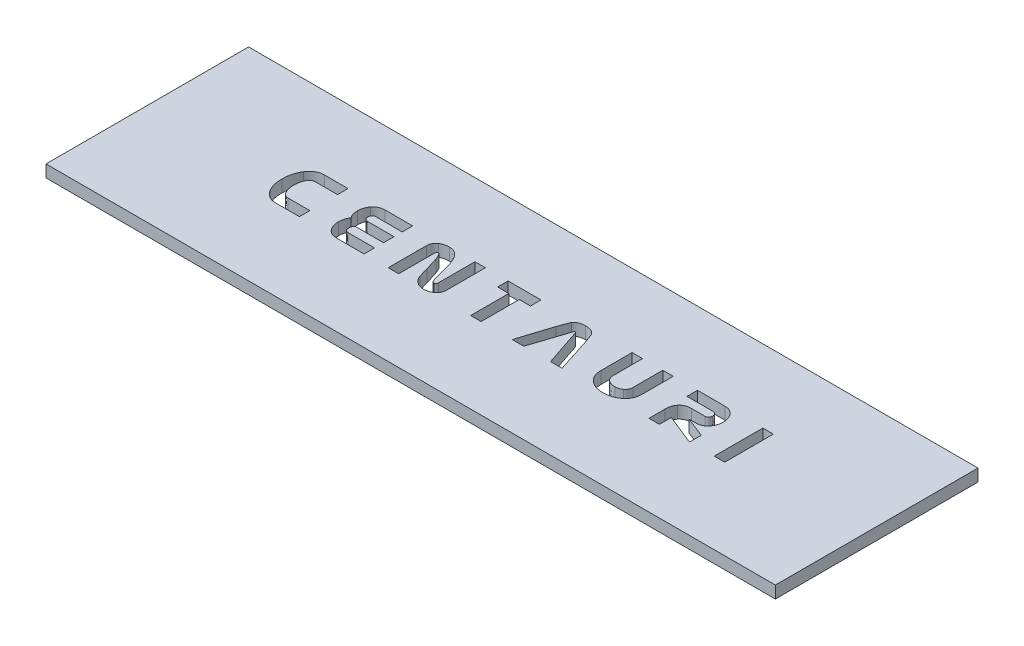
from build123d import *

# Parameters (mm, degrees)
SKETCH1_W           = 180
SKETCH1_H           = 50
BOSS_EXTRUDE1_DEPTH = 3
SKETCH3_W           = 2.584615384
SKETCH3_H           = 12
CUT_EXTRUDE2_DEPTH  = 4


with BuildPart() as part:
    # Sketch1 → Boss-Extrude1 (new body)
    with BuildSketch(Plane(origin=(0, 0, 0), x_dir=(1, 0, 0), z_dir=(0, 1, 0))):
        with Locations((55.306122449, 6.37755102)):
            Rectangle(SKETCH1_W, SKETCH1_H)
    extrude(amount=BOSS_EXTRUDE1_DEPTH)

    # Sketch3 → Cut-Extrude2 (cut, through all)
    with BuildSketch(Plane(origin=(0, 3, 0), x_dir=(1, 0, 0), z_dir=(0, 1, 0))):
        with Locations((111.503045526, 7.37755102)):
            Rectangle(SKETCH3_W, SKETCH3_H)
        with BuildLine():
            Line((104.151314757, 1.331397174), (96.659968603, 4.331397174))
            Line((96.659968603, 4.331397174), (96.659968603, 1.417935636))
            Line((96.659968603, 1.417935636), (94.075353218, 1.417935636))
            Line((94.075353218, 1.417935636), (94.075353218, 5.404474097))
            add(Edge.make_bspline(
                [(94.075353218, 5.404474097), (94.077783488, 5.521837057), (94.082513805, 5.750274291), (94.113135102, 6.085283936), (94.171906372, 6.40214741), (94.249023069, 6.702240314), (94.346736519, 6.986260441), (94.472234096, 7.250443105), (94.614933359, 7.501708858), (94.730342412, 7.653722459), (94.787853218, 7.729474097)],
                knots=[0, 0, 0, 0, 0.000352112, 0.000685357, 0.001007867, 0.001317812, 0.001614311, 0.001907252, 0.002194209, 0.002479247, 0.002479247, 0.002479247, 0.002479247], degree=3))
            add(Edge.make_bspline(
                [(94.787853218, 7.729474097), (94.858869169, 7.81223259), (95.000127593, 7.976848201), (95.247649926, 8.187452071), (95.519848388, 8.364884657), (95.814318465, 8.513126474), (96.135551196, 8.625227764), (96.479630594, 8.70614626), (96.849155289, 8.751411211), (97.103118036, 8.758508537), (97.234007064, 8.762166405)],
                knots=[0, 0, 0, 0, 0.000326765, 0.00064997, 0.000970799, 0.001299759, 0.001636419, 0.001989063, 0.002358305, 0.002750994, 0.002750994, 0.002750994, 0.002750994], degree=3))
            Line((97.234007064, 8.762166405), (100.510930141, 8.762166405))
            add(Edge.make_bspline(
                [(100.510930141, 8.762166405), (100.582506607, 8.764842157), (100.719370969, 8.769958574), (100.912485676, 8.826987129), (101.080457951, 8.919399509), (101.21680336, 9.050471952), (101.325976171, 9.202402027), (101.40501475, 9.372650343), (101.452672185, 9.556691576), (101.457509793, 9.683998568), (101.459968603, 9.748704867)],
                knots=[0, 0, 0, 0, 0.000214162, 0.000409508, 0.00059807, 0.000783787, 0.000971907, 0.001156455, 0.001343955, 0.001537761, 0.001537761, 0.001537761, 0.001537761], degree=3))
            add(Edge.make_bspline(
                [(101.459968603, 9.748704867), (101.457278055, 9.817200113), (101.452028991, 9.950829395), (101.408943785, 10.142726249), (101.333467911, 10.317405253), (101.260032365, 10.417222523), (101.223430141, 10.466974097)],
                knots=[0, 0, 0, 0, 0.000205315, 0.000400555, 0.00058654, 0.000771358, 0.000771358, 0.000771358, 0.000771358], degree=3))
            add(Edge.make_bspline(
                [(101.223430141, 10.466974097), (101.1773741, 10.516398285), (101.086408664, 10.61401616), (100.91438126, 10.719976414), (100.718964682, 10.782200501), (100.581583484, 10.789289736), (100.510930141, 10.792935636)],
                knots=[0, 0, 0, 0, 0.000201944, 0.00039886, 0.000598649, 0.000810192, 0.000810192, 0.000810192, 0.000810192], degree=3))
            Line((100.510930141, 10.792935636), (94.075353218, 10.792935636))
            Line((94.075353218, 10.792935636), (94.075353218, 13.37755102))
            Line((94.075353218, 13.37755102), (100.842660911, 13.37755102))
            add(Edge.make_bspline(
                [(100.842660911, 13.37755102), (100.965911388, 13.374331483), (101.206824993, 13.36803836), (101.559363075, 13.315630576), (101.8906306, 13.225692139), (102.204525917, 13.104512245), (102.495635968, 12.944070138), (102.770199204, 12.752779251), (103.02296361, 12.52360253), (103.170599149, 12.347644425), (103.245545526, 12.258320251)],
                knots=[0, 0, 0, 0, 0.000369636, 0.000722516, 0.001066088, 0.001397668, 0.001729411, 0.002060728, 0.002399716, 0.002749231, 0.002749231, 0.002749231, 0.002749231], degree=3))
            add(Edge.make_bspline(
                [(103.245545526, 12.258320251), (103.309833471, 12.172992361), (103.437980211, 12.00290618), (103.598364999, 11.725901775), (103.738203601, 11.437316772), (103.850902807, 11.1329641), (103.936700108, 10.814032071), (104.000599355, 10.481570877), (104.038831679, 10.134221551), (104.042643998, 9.897839637), (104.044583987, 9.77755102)],
                knots=[0, 0, 0, 0, 0.000320244, 0.000638351, 0.000958322, 0.001281425, 0.001610322, 0.001948068, 0.002296247, 0.002657009, 0.002657009, 0.002657009, 0.002657009], degree=3))
            add(Edge.make_bspline(
                [(104.044583987, 9.77755102), (104.042666603, 9.658218674), (104.038899162, 9.423744332), (104.000252719, 9.078392089), (103.937197062, 8.747666674), (103.850335233, 8.429986266), (103.738268273, 8.12642179), (103.598347939, 7.837858682), (103.437984499, 7.560848558), (103.309834903, 7.390763142), (103.245545526, 7.305435636)],
                knots=[0, 0, 0, 0, 0.000357878, 0.00070319, 0.001040936, 0.001367051, 0.001690154, 0.002010125, 0.002328231, 0.002648476, 0.002648476, 0.002648476, 0.002648476], degree=3))
            add(Edge.make_bspline(
                [(103.245545526, 7.305435636), (103.17079576, 7.214948537), (103.023995192, 7.037241524), (102.769150269, 6.808596118), (102.496729912, 6.613234038), (102.203712279, 6.454410956), (101.891382536, 6.328517828), (101.559249404, 6.239745411), (101.206855323, 6.186990588), (100.965921652, 6.18074582), (100.842660911, 6.17755102)],
                knots=[0, 0, 0, 0, 0.000351687, 0.000690675, 0.001023657, 0.001355401, 0.001688046, 0.002031618, 0.002384497, 0.002754134, 0.002754134, 0.002754134, 0.002754134], degree=3))
            Line((100.842660911, 6.17755102), (99.207083987, 6.17755102))
            Line((99.207083987, 6.17755102), (104.151314757, 4.22755102))
            Line((104.151314757, 4.22755102), (104.151314757, 1.331397174))
        make_face()
        with BuildLine():
            add(Edge.make_bspline(
                [(88.093814757, 5.649666405), (88.088908157, 5.479175628), (88.079322441, 5.146098519), (88.002005461, 4.660533714), (87.879096718, 4.200989134), (87.701799908, 3.767678029), (87.471777305, 3.361572423), (87.193160226, 2.982032936), (86.86494128, 2.628148362), (86.6128026, 2.422716216), (86.484199372, 2.317935636)],
                knots=[0, 0, 0, 0, 0.000511237, 0.000998771, 0.001471117, 0.001935549, 0.002399255, 0.002867745, 0.003345321, 0.003842489, 0.003842489, 0.003842489, 0.003842489], degree=3))
            add(Edge.make_bspline(
                [(86.484199372, 2.317935636), (86.361674204, 2.228175768), (86.116018196, 2.048212327), (85.720443172, 1.819309926), (85.305950446, 1.623832211), (84.869444573, 1.468785737), (84.414394739, 1.344798387), (83.938123961, 1.254604623), (83.44209488, 1.202790729), (83.10451149, 1.196252712), (82.933237834, 1.192935636)],
                knots=[0, 0, 0, 0, 0.000455386, 0.000913022, 0.001368554, 0.001828431, 0.002300777, 0.002782232, 0.003281095, 0.003794848, 0.003794848, 0.003794848, 0.003794848], degree=3))
            add(Edge.make_bspline(
                [(82.933237834, 1.192935636), (82.766748331, 1.196112671), (82.439666017, 1.202354218), (81.958470147, 1.255965147), (81.497135861, 1.341114963), (81.056000515, 1.462633657), (80.636685166, 1.619305377), (80.235329921, 1.807523208), (79.853371451, 2.030872861), (79.618127464, 2.208806704), (79.500545526, 2.297743328)],
                knots=[0, 0, 0, 0, 0.000499339, 0.000980992, 0.001450573, 0.001905465, 0.002351798, 0.002791822, 0.003234101, 0.003676078, 0.003676078, 0.003676078, 0.003676078], degree=3))
            add(Edge.make_bspline(
                [(79.500545526, 2.297743328), (79.375870089, 2.402690242), (79.130792805, 2.608986731), (78.811428291, 2.962038529), (78.541471121, 3.341707351), (78.319991898, 3.749186129), (78.148669968, 4.185260839), (78.029751535, 4.64947359), (77.950671097, 5.140237987), (77.9435913, 5.47722953), (77.939968603, 5.649666405)],
                knots=[0, 0, 0, 0, 0.000488455, 0.000960167, 0.001423594, 0.001883109, 0.002348069, 0.002825244, 0.00331848, 0.003835342, 0.003835342, 0.003835342, 0.003835342], degree=3))
            Line((77.939968603, 5.649666405), (77.939968603, 13.37755102))
            Line((77.939968603, 13.37755102), (80.524583987, 13.37755102))
            Line((80.524583987, 13.37755102), (80.524583987, 6.018897174))
            add(Edge.make_bspline(
                [(80.524583987, 6.018897174), (80.526575463, 5.941831532), (80.530508435, 5.789634341), (80.568342336, 5.56746499), (80.632877855, 5.35775274), (80.720167918, 5.15879812), (80.832590856, 4.971712835), (80.970296286, 4.796572317), (81.132719016, 4.633423035), (81.257033091, 4.538628484), (81.320737834, 4.49005102)],
                knots=[0, 0, 0, 0, 0.000231058, 0.000456316, 0.000673488, 0.000887883, 0.001106543, 0.0013264, 0.00155485, 0.001794967, 0.001794967, 0.001794967, 0.001794967], degree=3))
            add(Edge.make_bspline(
                [(81.320737834, 4.49005102), (81.446072659, 4.40826064), (81.697974565, 4.243875742), (82.128374669, 4.08346305), (82.591452385, 3.977039084), (82.914321348, 3.967217202), (83.080353218, 3.962166405)],
                knots=[0, 0, 0, 0, 0.000447711, 0.000899823, 0.001369457, 0.001866625, 0.001866625, 0.001866625, 0.001866625], degree=3))
            add(Edge.make_bspline(
                [(83.080353218, 3.962166405), (83.239583082, 3.967688164), (83.547641306, 3.97837098), (83.989271864, 4.077136065), (84.396038764, 4.232999572), (84.632842561, 4.391216988), (84.750545526, 4.469858713)],
                knots=[0, 0, 0, 0, 0.000477018, 0.000922875, 0.001351404, 0.001774902, 0.001774902, 0.001774902, 0.001774902], degree=3))
            add(Edge.make_bspline(
                [(84.750545526, 4.469858713), (84.81157644, 4.51731231), (84.931223106, 4.610341634), (85.083787839, 4.774684242), (85.215956847, 4.94873293), (85.323361318, 5.13796288), (85.406690015, 5.340718152), (85.468126465, 5.555291736), (85.502863346, 5.783142798), (85.507051358, 5.938972666), (85.509199372, 6.018897174)],
                knots=[0, 0, 0, 0, 0.000231579, 0.000453994, 0.00067034, 0.000886089, 0.001104655, 0.001326545, 0.001554193, 0.001793893, 0.001793893, 0.001793893, 0.001793893], degree=3))
            Line((85.509199372, 6.018897174), (85.509199372, 13.37755102))
            Line((85.509199372, 13.37755102), (88.093814757, 13.37755102))
            Line((88.093814757, 13.37755102), (88.093814757, 5.649666405))
        make_face()
        with BuildLine():
            Line((72.633430141, 1.37755102), (69.820930141, 1.37755102))
            Line((69.820930141, 1.37755102), (66.714199372, 10.645820251))
            add(Edge.make_bspline(
                [(66.714199372, 10.645820251), (66.708311345, 10.667915948), (66.696906966, 10.710712579), (66.648929228, 10.759425628), (66.584696737, 10.790091043), (66.535757237, 10.791939697), (66.50939168, 10.792935636)],
                knots=[0, 0, 0, 0, 6.7527e-05, 0.000130792, 0.000197886, 0.00027625, 0.00027625, 0.00027625, 0.00027625], degree=3))
            add(Edge.make_bspline(
                [(66.50939168, 10.792935636), (66.48296064, 10.79197614), (66.433017443, 10.790163109), (66.365693074, 10.756535967), (66.305918896, 10.711861635), (66.280195484, 10.668117236), (66.267083987, 10.645820251)],
                knots=[0, 0, 0, 0, 7.8364e-05, 0.000148074, 0.000221956, 0.000298765, 0.000298765, 0.000298765, 0.000298765], degree=3))
            Line((66.267083987, 10.645820251), (63.229583987, 1.37755102))
            Line((63.229583987, 1.37755102), (60.376699372, 1.37755102))
            add(Edge.make_bspline(
                [(60.376699372, 1.37755102), (60.399650313, 1.45739562), (60.450588918, 1.634607199), (60.53762173, 1.925812656), (60.641196381, 2.270426899), (60.765873965, 2.665792097), (60.904433736, 3.115096739), (61.059582094, 3.61751737), (61.236329141, 4.171474134), (61.487266445, 4.976851895), (61.818954301, 5.998724381), (62.209248426, 7.215388104), (62.599174263, 8.395378603), (62.857330715, 9.170866712), (62.98439168, 9.55255102)],
                knots=[0, 0, 0, 0, 0.000249231, 0.000553158, 0.000911791, 0.001328746, 0.001796809, 0.002322348, 0.002906224, 0.003541207, 0.004853025, 0.006129242, 0.007374397, 0.008581232, 0.008581232, 0.008581232, 0.008581232], degree=3))
            add(Edge.make_bspline(
                [(62.98439168, 9.55255102), (63.051380855, 9.75073805), (63.177670049, 10.124363793), (63.359953321, 10.647875277), (63.51756529, 11.10376441), (63.659306524, 11.487528949), (63.776144517, 11.80393517), (63.87507991, 12.047334124), (63.946520035, 12.225241682), (63.997233266, 12.315354866), (64.017083987, 12.350627943)],
                knots=[0, 0, 0, 0, 0.000627601, 0.001183165, 0.001663035, 0.002074606, 0.002410537, 0.002674617, 0.002863245, 0.002984571, 0.002984571, 0.002984571, 0.002984571], degree=3))
            add(Edge.make_bspline(
                [(64.017083987, 12.350627943), (64.080131579, 12.430628551), (64.208232557, 12.593174907), (64.447394803, 12.800806597), (64.727397335, 12.974593601), (65.040356712, 13.120507366), (65.381775253, 13.233094149), (65.741552369, 13.318126921), (66.116703488, 13.366963488), (66.371756004, 13.37399509), (66.500737834, 13.37755102)],
                knots=[0, 0, 0, 0, 0.000305075, 0.000619855, 0.000943973, 0.001291111, 0.001653254, 0.002020598, 0.002398791, 0.002785716, 0.002785716, 0.002785716, 0.002785716], degree=3))
            add(Edge.make_bspline(
                [(66.500737834, 13.37755102), (66.629723751, 13.374033765), (66.883830913, 13.367104637), (67.257054599, 13.318102434), (67.614010567, 13.233185409), (67.953199745, 13.119879808), (68.265485184, 12.974684472), (68.545282576, 12.800675681), (68.784619696, 12.594000412), (68.910895528, 12.430734801), (68.972853218, 12.350627943)],
                knots=[0, 0, 0, 0, 0.000386926, 0.000762258, 0.001126794, 0.001486204, 0.001833342, 0.00215746, 0.002472241, 0.002775468, 0.002775468, 0.002775468, 0.002775468], degree=3))
            add(Edge.make_bspline(
                [(68.972853218, 12.350627943), (68.994627602, 12.315389562), (69.050567332, 12.224859999), (69.130505471, 12.046805365), (69.230745667, 11.800935288), (69.350782595, 11.486928441), (69.492493083, 11.105330682), (69.653456243, 10.65509422), (69.835223036, 10.137154177), (69.959803532, 9.76807742), (70.025737834, 9.572743328)],
                knots=[0, 0, 0, 0, 0.000124173, 0.000319007, 0.000584172, 0.000921129, 0.001327287, 0.001805402, 0.002355518, 0.002973997, 0.002973997, 0.002973997, 0.002973997], degree=3))
            add(Edge.make_bspline(
                [(70.025737834, 9.572743328), (70.07084914, 9.436178371), (70.166794093, 9.14572528), (70.321527361, 8.683182118), (70.486595247, 8.164829599), (70.672119195, 7.593009887), (70.874426147, 6.967477757), (71.090052452, 6.287435619), (71.321297542, 5.55266658), (71.480588109, 5.044872116), (71.563237834, 4.781397174)],
                knots=[0, 0, 0, 0, 0.000431469, 0.00091767, 0.001463191, 0.00206344, 0.002721164, 0.003435484, 0.004203659, 0.005032061, 0.005032061, 0.005032061, 0.005032061], degree=3))
            add(Edge.make_bspline(
                [(71.563237834, 4.781397174), (71.662989155, 4.462088148), (71.855051936, 3.847285472), (72.13616428, 2.961460481), (72.392214723, 2.145861252), (72.555545021, 1.625627759), (72.633430141, 1.37755102)],
                knots=[0, 0, 0, 0, 0.001003581, 0.001932311, 0.002788074, 0.003568122, 0.003568122, 0.003568122, 0.003568122], degree=3))
        make_face()
        Polygon((55.453814757, 10.792935636), (52.684583987, 10.792935636), (52.684583987, 1.37755102), (50.099968603, 1.37755102), (50.099968603, 10.792935636), (47.330737834, 10.792935636), (47.330737834, 13.37755102), (55.453814757, 13.37755102), align=None)
        with BuildLine():
            add(Edge.make_bspline(
                [(41.718430141, 3.766012559), (41.715665838, 3.673557902), (41.710221065, 3.491452437), (41.666829372, 3.223634253), (41.589760077, 2.969258542), (41.490519921, 2.724283936), (41.354774646, 2.495266741), (41.192216618, 2.276948801), (40.998962395, 2.07229388), (40.852432386, 1.950140074), (40.778045526, 1.888127943)],
                knots=[0, 0, 0, 0, 0.000277298, 0.000546187, 0.000810881, 0.001073381, 0.001337083, 0.001607084, 0.001888685, 0.002179044, 0.002179044, 0.002179044, 0.002179044], degree=3))
            add(Edge.make_bspline(
                [(40.778045526, 1.888127943), (40.703973054, 1.832921586), (40.556210709, 1.722794022), (40.318011671, 1.581991885), (40.070487124, 1.460540186), (39.811115891, 1.36069697), (39.540887621, 1.288105909), (39.260806268, 1.231161033), (38.970085359, 1.200319049), (38.772340667, 1.195416476), (38.672276295, 1.192935636)],
                knots=[0, 0, 0, 0, 0.000276983, 0.000552536, 0.000828616, 0.001103443, 0.001384778, 0.001667073, 0.001960142, 0.002260363, 0.002260363, 0.002260363, 0.002260363], degree=3))
            add(Edge.make_bspline(
                [(38.672276295, 1.192935636), (38.49953477, 1.199118564), (38.160416325, 1.211256613), (37.667842018, 1.321173938), (37.197627214, 1.487553168), (36.914041236, 1.658074963), (36.771314757, 1.743897174)],
                knots=[0, 0, 0, 0, 0.000517505, 0.001015943, 0.001507861, 0.002006299, 0.002006299, 0.002006299, 0.002006299], degree=3))
            add(Edge.make_bspline(
                [(36.771314757, 1.743897174), (36.693953524, 1.795948998), (36.540160657, 1.899427173), (36.33543362, 2.085582866), (36.137524337, 2.276595425), (35.967000539, 2.493359366), (35.804994999, 2.721226101), (35.666760546, 2.969317482), (35.53893187, 3.231033781), (35.472501924, 3.415303615), (35.438622449, 3.50928179)],
                knots=[0, 0, 0, 0, 0.000279331, 0.000555306, 0.00082863, 0.001103442, 0.001381115, 0.001666634, 0.001954359, 0.002253832, 0.002253832, 0.002253832, 0.002253832], degree=3))
            add(Edge.make_bspline(
                [(35.438622449, 3.50928179), (35.428905635, 3.539057686), (35.402673714, 3.619441958), (35.357052558, 3.773472892), (35.293675121, 3.990534991), (35.217426677, 4.273553833), (35.113828913, 4.617168643), (35.00042327, 5.027627491), (34.867089574, 5.500520836), (34.773152894, 5.837142283), (34.723237834, 6.016012559)],
                knots=[0, 0, 0, 0, 9.3961e-05, 0.00025366, 0.000481891, 0.000772336, 0.001132913, 0.00155847, 0.002049804, 0.002606915, 0.002606915, 0.002606915, 0.002606915], degree=3))
            add(Edge.make_bspline(
                [(34.723237834, 6.016012559), (34.676434767, 6.183409012), (34.585140145, 6.509934538), (34.447042232, 6.983819765), (34.313422142, 7.429704107), (34.187057891, 7.848442083), (34.064491919, 8.23935558), (33.941549779, 8.600970369), (33.827414638, 8.935074311), (33.750452328, 9.147845807), (33.713622449, 9.249666405)],
                knots=[0, 0, 0, 0, 0.000521446, 0.001017138, 0.001480763, 0.001917866, 0.002329315, 0.002709702, 0.003063653, 0.003388476, 0.003388476, 0.003388476, 0.003388476], degree=3))
            add(Edge.make_bspline(
                [(33.713622449, 9.249666405), (33.665455838, 9.374063625), (33.575296997, 9.60691183), (33.436108631, 9.927934432), (33.308555563, 10.20020028), (33.185533131, 10.420677697), (33.068705634, 10.591656369), (32.957326388, 10.709210615), (32.850566019, 10.785443032), (32.776919993, 10.790640149), (32.74439168, 10.792935636)],
                knots=[0, 0, 0, 0, 0.000400141, 0.000748989, 0.001049612, 0.0013015, 0.001506389, 0.001667541, 0.001789243, 0.001885522, 0.001885522, 0.001885522, 0.001885522], degree=3))
            add(Edge.make_bspline(
                [(32.74439168, 10.792935636), (32.706582551, 10.782341663), (32.635185184, 10.762336394), (32.537920096, 10.719326347), (32.458982154, 10.664927143), (32.376347601, 10.574868604), (32.315293235, 10.417226896), (32.307396872, 10.281920333), (32.303045526, 10.207358713)],
                knots=[0, 0, 0, 0, 0.000117705, 0.00022227, 0.000317506, 0.000403272, 0.00058546, 0.000809087, 0.000809087, 0.000809087, 0.000809087], degree=3))
            Line((32.303045526, 10.207358713), (32.303045526, 1.417935636))
            Line((32.303045526, 1.417935636), (29.718430141, 1.417935636))
            Line((29.718430141, 1.417935636), (29.718430141, 10.839089482))
            add(Edge.make_bspline(
                [(29.718430141, 10.839089482), (29.720431388, 10.943192399), (29.724346721, 11.146864283), (29.777317807, 11.441052853), (29.849410441, 11.719647028), (29.96043279, 11.975891726), (30.100177435, 12.214861497), (30.275159659, 12.429257918), (30.475844677, 12.630948576), (30.631105507, 12.743104076), (30.710737834, 12.800627943)],
                knots=[0, 0, 0, 0, 0.000311872, 0.000610161, 0.000894278, 0.00117343, 0.001445029, 0.001722087, 0.002001538, 0.002295783, 0.002295783, 0.002295783, 0.002295783], degree=3))
            add(Edge.make_bspline(
                [(30.710737834, 12.800627943), (30.784085224, 12.84698996), (30.931247192, 12.940009295), (31.167008585, 13.059617441), (31.419720466, 13.157088946), (31.687106767, 13.236983211), (31.969420268, 13.300937997), (32.266169563, 13.347096991), (32.578550417, 13.372647446), (32.791461978, 13.375893695), (32.900160911, 13.37755102)],
                knots=[0, 0, 0, 0, 0.000260224, 0.000522105, 0.00079155, 0.001071714, 0.001358629, 0.001659307, 0.001971926, 0.002298002, 0.002298002, 0.002298002, 0.002298002], degree=3))
            add(Edge.make_bspline(
                [(32.900160911, 13.37755102), (33.045663879, 13.37159126), (33.331270775, 13.359892883), (33.748745392, 13.280024723), (34.138972267, 13.133868956), (34.510164215, 12.940864063), (34.85386653, 12.685452872), (35.178466456, 12.37941582), (35.475105267, 12.013789059), (35.64718842, 11.740998639), (35.735737834, 11.600627943)],
                knots=[0, 0, 0, 0, 0.000436531, 0.000856864, 0.001268435, 0.001682636, 0.00210786, 0.002548612, 0.003018061, 0.003515696, 0.003515696, 0.003515696, 0.003515696], degree=3))
            add(Edge.make_bspline(
                [(35.735737834, 11.600627943), (35.795942458, 11.495664802), (35.923377442, 11.273489575), (36.091684797, 10.905565012), (36.267164962, 10.496430445), (36.431835465, 10.038484506), (36.598975622, 9.536381142), (36.767130465, 8.988871395), (36.926924395, 8.393419975), (37.029678678, 7.980603435), (37.082853218, 7.766974097)],
                knots=[0, 0, 0, 0, 0.000362831, 0.000768004, 0.001212684, 0.001698192, 0.002227265, 0.00280031, 0.003416106, 0.004076551, 0.004076551, 0.004076551, 0.004076551], degree=3))
            add(Edge.make_bspline(
                [(37.082853218, 7.766974097), (37.139261886, 7.536124786), (37.246764837, 7.096174985), (37.404599509, 6.47190697), (37.551136905, 5.916880178), (37.688379019, 5.432036327), (37.806217196, 5.013072404), (37.91962828, 4.665798066), (38.015327241, 4.385461662), (38.083079744, 4.225344005), (38.112660911, 4.155435636)],
                knots=[0, 0, 0, 0, 0.00071292, 0.001358675, 0.001931727, 0.00243495, 0.002870412, 0.003237133, 0.00353091, 0.003758576, 0.003758576, 0.003758576, 0.003758576], degree=3))
            add(Edge.make_bspline(
                [(38.112660911, 4.155435636), (38.143587767, 4.098727146), (38.201652908, 3.992257014), (38.327860249, 3.866825036), (38.481865321, 3.788826919), (38.594459836, 3.781368252), (38.652083987, 3.77755102)],
                knots=[0, 0, 0, 0, 0.000192946, 0.000362256, 0.000526096, 0.000697846, 0.000697846, 0.000697846, 0.000697846], degree=3))
            add(Edge.make_bspline(
                [(38.652083987, 3.77755102), (38.714537264, 3.785777863), (38.842022177, 3.802571191), (38.975429095, 3.908022265), (39.056767196, 4.018923536), (39.104493227, 4.122664448), (39.128974268, 4.241793271), (39.132163129, 4.325527927), (39.133814757, 4.368897174)],
                knots=[0, 0, 0, 0, 0.000186164, 0.000380013, 0.000487327, 0.000598338, 0.000719423, 0.000849519, 0.000849519, 0.000849519, 0.000849519], degree=3))
            Line((39.133814757, 4.368897174), (39.133814757, 13.400627943))
            Line((39.133814757, 13.400627943), (41.718430141, 13.400627943))
            Line((41.718430141, 13.400627943), (41.718430141, 3.766012559))
        make_face()
        with BuildLine():
            Line((23.797468603, 1.37755102), (16.989776295, 1.37755102))
            add(Edge.make_bspline(
                [(16.989776295, 1.37755102), (16.865534756, 1.380519356), (16.622505489, 1.386325728), (16.268067103, 1.442220367), (15.933739004, 1.535579939), (15.618300489, 1.661568503), (15.3230958, 1.82582131), (15.047852808, 2.024976576), (14.794912824, 2.2644056), (14.645619148, 2.445125759), (14.569583987, 2.537166405)],
                knots=[0, 0, 0, 0, 0.000372518, 0.000728683, 0.001073017, 0.001412091, 0.001745224, 0.002083918, 0.002428783, 0.002786719, 0.002786719, 0.002786719, 0.002786719], degree=3))
            add(Edge.make_bspline(
                [(14.569583987, 2.537166405), (14.505627563, 2.625596377), (14.377766899, 2.802384167), (14.211824719, 3.086017589), (14.078352295, 3.387381966), (13.964125893, 3.701249334), (13.875196759, 4.02927467), (13.811569446, 4.372633067), (13.773421378, 4.730521598), (13.769603049, 4.974572099), (13.767660911, 5.098704867)],
                knots=[0, 0, 0, 0, 0.000327299, 0.000654331, 0.000983544, 0.001314773, 0.00165556, 0.00200181, 0.002361463, 0.002733757, 0.002733757, 0.002733757, 0.002733757], degree=3))
            add(Edge.make_bspline(
                [(13.767660911, 5.098704867), (13.770037216, 5.211277048), (13.774718087, 5.433022929), (13.806854812, 5.758814257), (13.859276551, 6.072866212), (13.930096653, 6.376273791), (14.026343992, 6.668010124), (14.141288508, 6.947924237), (14.277338404, 7.216817055), (14.385402887, 7.385157186), (14.439776295, 7.469858713)],
                knots=[0, 0, 0, 0, 0.000337697, 0.000665199, 0.000981035, 0.001292387, 0.00159889, 0.001901555, 0.002199565, 0.002501362, 0.002501362, 0.002501362, 0.002501362], degree=3))
            add(Edge.make_bspline(
                [(14.439776295, 7.469858713), (14.385418272, 7.552625355), (14.27743838, 7.717037755), (14.141256676, 7.980135464), (14.026901413, 8.253556008), (13.930545201, 8.536513605), (13.858851269, 8.83015375), (13.807142709, 9.133785895), (13.774654095, 9.448968029), (13.770016395, 9.663049811), (13.767660911, 9.77178179)],
                knots=[0, 0, 0, 0, 0.000296905, 0.00058979, 0.000887129, 0.001185418, 0.001485557, 0.00179286, 0.00210888, 0.002435046, 0.002435046, 0.002435046, 0.002435046], degree=3))
            add(Edge.make_bspline(
                [(13.767660911, 9.77178179), (13.769563185, 9.891117908), (13.773300935, 10.12559966), (13.812162502, 10.47089821), (13.874652274, 10.802984603), (13.964806824, 11.121067589), (14.077619782, 11.424911121), (14.21265022, 11.7160767), (14.37857887, 11.990832333), (14.505717224, 12.163119538), (14.569583987, 12.249666405)],
                knots=[0, 0, 0, 0, 0.000357878, 0.00070319, 0.001040936, 0.001370604, 0.001693706, 0.00201244, 0.002332021, 0.002654608, 0.002654608, 0.002654608, 0.002654608], degree=3))
            add(Edge.make_bspline(
                [(14.569583987, 12.249666405), (14.645459418, 12.339991719), (14.794077776, 12.516913283), (15.048977242, 12.747659992), (15.323942849, 12.940771427), (15.618393935, 13.102355113), (15.933909198, 13.225242623), (16.268226617, 13.31594928), (16.622750683, 13.367983948), (16.865568921, 13.374313369), (16.989776295, 13.37755102)],
                knots=[0, 0, 0, 0, 0.000353586, 0.000692574, 0.00102791, 0.001359653, 0.001697659, 0.002041231, 0.002396963, 0.002769481, 0.002769481, 0.002769481, 0.002769481], degree=3))
            Line((16.989776295, 13.37755102), (23.797468603, 13.37755102))
            Line((23.797468603, 13.37755102), (23.797468603, 10.792935636))
            Line((23.797468603, 10.792935636), (17.301314757, 10.792935636))
            add(Edge.make_bspline(
                [(17.301314757, 10.792935636), (17.231639264, 10.789200721), (17.097380829, 10.782003874), (16.906508813, 10.722120471), (16.739062457, 10.622836172), (16.600662462, 10.485039039), (16.492637295, 10.322695986), (16.40908224, 10.145505085), (16.363185055, 9.950962482), (16.355970291, 9.817194665), (16.352276295, 9.748704867)],
                knots=[0, 0, 0, 0, 0.000208672, 0.000402091, 0.000593544, 0.000787329, 0.000982547, 0.001176161, 0.00137206, 0.001577598, 0.001577598, 0.001577598, 0.001577598], degree=3))
            add(Edge.make_bspline(
                [(16.352276295, 9.748704867), (16.354680062, 9.68303951), (16.359375359, 9.554774795), (16.407059687, 9.369653406), (16.486665778, 9.200437847), (16.592360483, 9.046906343), (16.728300378, 8.916155343), (16.897717497, 8.82762117), (17.090808396, 8.769468269), (17.228727806, 8.764684239), (17.301314757, 8.762166405)],
                knots=[0, 0, 0, 0, 0.000196683, 0.000384183, 0.000568731, 0.000755185, 0.000940902, 0.001128069, 0.001323415, 0.001540452, 0.001540452, 0.001540452, 0.001540452], degree=3))
            Line((17.301314757, 8.762166405), (23.797468603, 8.762166405))
            Line((23.797468603, 8.762166405), (23.797468603, 6.24678179))
            Line((23.797468603, 6.24678179), (23.797468603, 6.17755102))
            Line((23.797468603, 6.17755102), (16.932083987, 6.17755102))
            add(Edge.make_bspline(
                [(16.932083987, 6.17755102), (16.888846969, 6.154984098), (16.801305603, 6.109293177), (16.686195976, 6.012822617), (16.585486563, 5.893382675), (16.472527373, 5.70605294), (16.371440976, 5.433791467), (16.358763998, 5.202599183), (16.352276295, 5.08428179)],
                knots=[0, 0, 0, 0, 0.00014598, 0.000295563, 0.000446999, 0.000612732, 0.000950368, 0.001304283, 0.001304283, 0.001304283, 0.001304283], degree=3))
            add(Edge.make_bspline(
                [(16.352276295, 5.08428179), (16.35470144, 5.010959944), (16.359443986, 4.867573773), (16.406878269, 4.659694919), (16.486432356, 4.467716917), (16.590046485, 4.291953964), (16.72646469, 4.143424732), (16.895312617, 4.038853699), (17.089623258, 3.971034147), (17.228593596, 3.965212689), (17.301314757, 3.962166405)],
                knots=[0, 0, 0, 0, 0.000219705, 0.000429648, 0.000635348, 0.000841149, 0.001039097, 0.001233568, 0.001431517, 0.001648803, 0.001648803, 0.001648803, 0.001648803], degree=3))
            Line((17.301314757, 3.962166405), (23.797468603, 3.962166405))
            Line((23.797468603, 3.962166405), (23.797468603, 1.37755102))
        make_face()
        with BuildLine():
            Line((7.846699372, 1.37755102), (2.034199372, 1.37755102))
            add(Edge.make_bspline(
                [(2.034199372, 1.37755102), (1.863622553, 1.382807179), (1.52979016, 1.393093899), (1.043031894, 1.482308864), (0.584721617, 1.626835137), (0.151686124, 1.82722544), (-0.250345622, 2.089744021), (-0.626421922, 2.408179807), (-0.974194714, 2.784317377), (-1.174760971, 3.069299193), (-1.277339089, 3.21505102)],
                knots=[0, 0, 0, 0, 0.000511391, 0.001000833, 0.001478879, 0.00194992, 0.002427592, 0.002914759, 0.0034251, 0.003959346, 0.003959346, 0.003959346, 0.003959346], degree=3))
            add(Edge.make_bspline(
                [(-1.277339089, 3.21505102), (-1.36583823, 3.354758103), (-1.543704359, 3.635542277), (-1.75854011, 4.088946364), (-1.949549747, 4.560741231), (-2.100477605, 5.059437581), (-2.223073284, 5.580305464), (-2.304220988, 6.126517439), (-2.358493756, 6.69472048), (-2.364610281, 7.082226441), (-2.367723705, 7.279474097)],
                knots=[0, 0, 0, 0, 0.000495701, 0.000996263, 0.001502461, 0.002021636, 0.002557624, 0.003106345, 0.003676982, 0.004268581, 0.004268581, 0.004268581, 0.004268581], degree=3))
            add(Edge.make_bspline(
                [(-2.367723705, 7.279474097), (-2.364525246, 7.480551937), (-2.358239721, 7.875704771), (-2.305024099, 8.456706435), (-2.219394423, 9.014803711), (-2.098112236, 9.549825502), (-1.94281046, 10.063498683), (-1.748654078, 10.552445371), (-1.524513386, 11.021636305), (-1.346180964, 11.315468065), (-1.257146782, 11.462166405)],
                knots=[0, 0, 0, 0, 0.000603133, 0.001185261, 0.001748677, 0.002295911, 0.002829721, 0.003356817, 0.003872873, 0.004387403, 0.004387403, 0.004387403, 0.004387403], degree=3))
            add(Edge.make_bspline(
                [(-1.257146782, 11.462166405), (-1.153774311, 11.614702602), (-0.952880043, 11.911141756), (-0.603380807, 12.302704143), (-0.22987714, 12.635776256), (0.172309598, 12.906443218), (0.599367745, 13.119971686), (1.054819127, 13.270514109), (1.536267581, 13.362242907), (1.86648442, 13.372394893), (2.034199372, 13.37755102)],
                knots=[0, 0, 0, 0, 0.000552289, 0.00107332, 0.001569918, 0.002049953, 0.002523399, 0.00299774, 0.003484865, 0.003987616, 0.003987616, 0.003987616, 0.003987616], degree=3))
            Line((2.034199372, 13.37755102), (7.846699372, 13.37755102))
            Line((7.846699372, 13.37755102), (7.846699372, 10.792935636))
            Line((7.846699372, 10.792935636), (2.438045526, 10.792935636))
            add(Edge.make_bspline(
                [(2.438045526, 10.792935636), (2.358989727, 10.78922446), (2.203373385, 10.781919246), (1.975309375, 10.735424071), (1.759577432, 10.654453486), (1.560034468, 10.53659865), (1.371806568, 10.390233398), (1.199241246, 10.209751374), (1.039413416, 9.997104057), (0.947939215, 9.83918048), (0.900545526, 9.757358713)],
                knots=[0, 0, 0, 0, 0.000237171, 0.000466856, 0.000695087, 0.000925152, 0.001159428, 0.001408309, 0.001671963, 0.001955435, 0.001955435, 0.001955435, 0.001955435], degree=3))
            add(Edge.make_bspline(
                [(0.900545526, 9.757358713), (0.822355969, 9.595888834), (0.661228016, 9.263142215), (0.512590474, 8.708624935), (0.418115806, 8.102972947), (0.40719121, 7.680842424), (0.401507064, 7.461204867)],
                knots=[0, 0, 0, 0, 0.000537158, 0.001106941, 0.001714, 0.002372458, 0.002372458, 0.002372458, 0.002372458], degree=3))
            add(Edge.make_bspline(
                [(0.401507064, 7.461204867), (0.40672382, 7.23478529), (0.416811187, 6.796969594), (0.519079677, 6.166747556), (0.673247716, 5.582563761), (0.839508379, 5.228445899), (0.920737834, 5.055435636)],
                knots=[0, 0, 0, 0, 0.000678627, 0.001312225, 0.001911337, 0.002483662, 0.002483662, 0.002483662, 0.002483662], degree=3))
            add(Edge.make_bspline(
                [(0.920737834, 5.055435636), (0.967752822, 4.968594698), (1.05840644, 4.801149265), (1.221880931, 4.579742292), (1.391712296, 4.387431809), (1.578927927, 4.234229146), (1.775056877, 4.109465213), (1.986982912, 4.026696291), (2.208300138, 3.971458149), (2.360782449, 3.965291206), (2.438045526, 3.962166405)],
                knots=[0, 0, 0, 0, 0.000295895, 0.00057054, 0.000823762, 0.001063463, 0.001294016, 0.001517922, 0.001743218, 0.001974635, 0.001974635, 0.001974635, 0.001974635], degree=3))
            Line((2.438045526, 3.962166405), (7.846699372, 3.962166405))
            Line((7.846699372, 3.962166405), (7.846699372, 1.37755102))
        make_face()
    extrude(amount=-CUT_EXTRUDE2_DEPTH, mode=Mode.SUBTRACT)


solid = part.part
